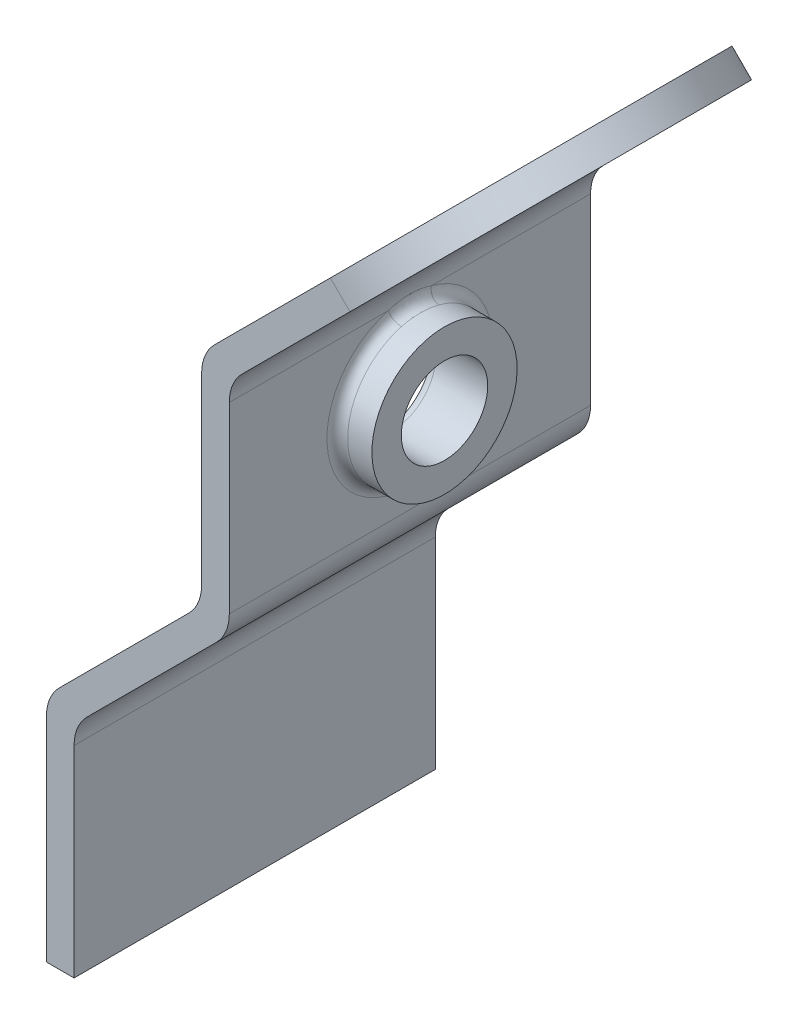
from build123d import *

# Parameters (mm, degrees)
BOSS_EXTRUDE1_DEPTH = 20.9
CUT_EXTRUDE1_DEPTH  = 57.895670946
SKETCH4_R           = 2.5
CUT_EXTRUDE2_DEPTH  = 57.389876565
SKETCH5_R           = 4.2
SKETCH5_R_2         = 2.5
BOSS_EXTRUDE2_DEPTH = 2
FILLET1_R           = 0.6


with BuildPart() as part:
    # Sketch1 → Boss-Extrude1 (new body)
    with BuildSketch(Plane.XY):
        with BuildLine():
            Line((1.6, 0), (1.6, 11.647897552))
            ThreePointArc((1.6, 11.647897552), (1.793345987, 12.61991347), (2.343948776, 13.443948776))
            Line((2.343948776, 13.443948776), (9.836307345, 20.936307345))
            ThreePointArc((9.836307345, 20.936307345), (10.386910134, 21.760342651), (10.580256121, 22.732358569))
            Line((10.580256121, 22.732358569), (10.580256121, 33.328153673))
            ThreePointArc((10.580256121, 33.328153673), (10.773602108, 34.300169591), (11.324204897, 35.124204897))
            Line((11.324204897, 35.124204897), (24.948665915, 48.748665915))
            Line((24.948665915, 48.748665915), (23.817295065, 49.880036765))
            Line((23.817295065, 49.880036765), (9.724204897, 35.786946597))
            ThreePointArc((9.724204897, 35.786946597), (9.173602108, 34.962911291), (8.980256121, 33.990895372))
            Line((8.980256121, 33.990895372), (8.980256121, 23.395100269))
            ThreePointArc((8.980256121, 23.395100269), (8.786910134, 22.423084351), (8.236307345, 21.599049045))
            Line((8.236307345, 21.599049045), (0.743948776, 14.106690476))
            ThreePointArc((0.743948776, 14.106690476), (0.193345987, 13.28265517), (0, 12.310639251))
            Line((0, 12.310639251), (0, 0))
            Line((0, 0), (1.6, 0))
        make_face()
    extrude(amount=-BOSS_EXTRUDE1_DEPTH)

    # Sketch3 → Cut-Extrude1 (cut, through all)
    with BuildSketch(Plane(origin=(-13.03137085, 13.03137085, 0), x_dir=(0, 0, 1), z_dir=(-0.7071067811865472, 0.7071067811865479, 0))):
        with BuildLine():
            ThreePointArc((-20.9, 41.661883092), (-17.839265863, 49.051148955), (-10.45, 52.111883092))
            Line((-10.45, 52.111883092), (-20.9, 52.111883092))
            Line((-20.9, 52.111883092), (-20.9, 41.661883092))
        make_face()
        with BuildLine():
            ThreePointArc((-10.45, 52.111883092), (-3.060734137, 49.051148955), (0, 41.661883092))
            Line((0, 41.661883092), (0, 52.111883092))
            Line((0, 52.111883092), (-10.45, 52.111883092))
        make_face()
    extrude(amount=-CUT_EXTRUDE1_DEPTH, mode=Mode.SUBTRACT)

    # Sketch4 → Cut-Extrude2 (cut, through all)
    with BuildSketch(Plane.ZY.offset(-8.980256121)):
        with Locations(Location((-10.45, 28.692997821, 0), (0, 0, 270))):
            Circle(SKETCH4_R)
    extrude(amount=-CUT_EXTRUDE2_DEPTH, mode=Mode.SUBTRACT)

    # Sketch5 → Boss-Extrude2 (add)
    with BuildSketch(Plane(origin=(10.580256121, 0, 0), x_dir=(0, 0, -1), z_dir=(1, 0, 0))):
        with Locations(Location((10.45, 28.692997821, 0), (0, 0, 90))):
            Circle(SKETCH5_R)
        with Locations(Location((10.45, 28.692997821, 0), (0, 0, 270))):
            Circle(SKETCH5_R_2, mode=Mode.SUBTRACT)
    extrude(amount=BOSS_EXTRUDE2_DEPTH)

    # Fillet1
    fillet1_edges = [part.edges().sort_by_distance(p)[0] for p in [
        (8.980256121, 31.192997821, -10.45),
        (10.580256121, 24.492997821, -10.45),
    ]]
    fillet(fillet1_edges, radius=FILLET1_R)


solid = part.part
